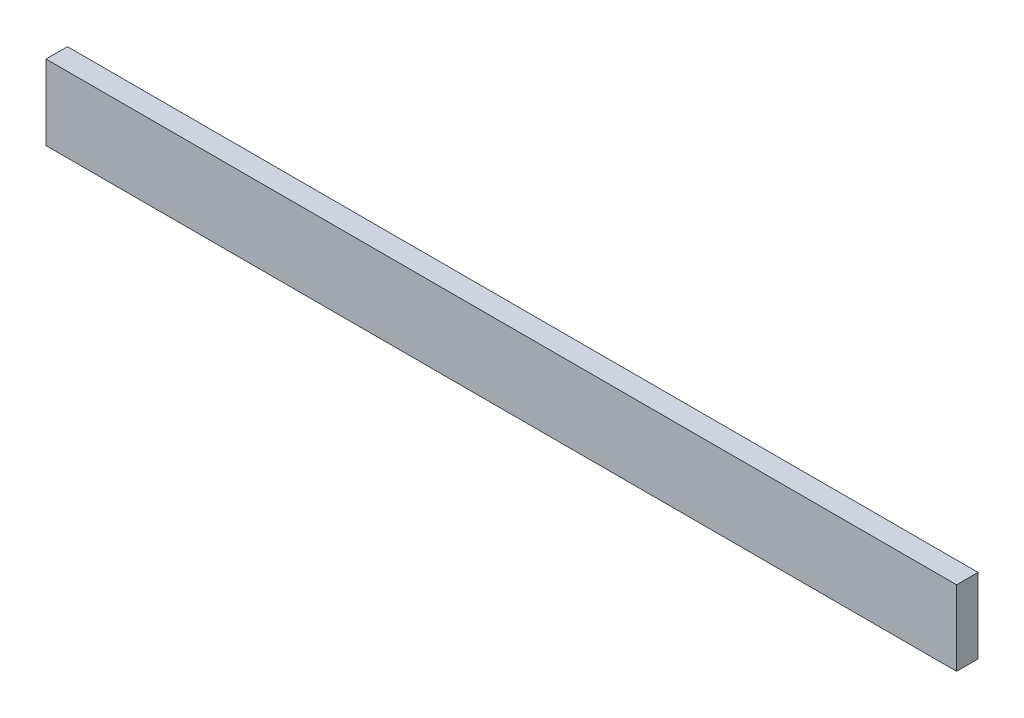
from build123d import *

# Parameters (mm, degrees)
SKETCH1_W           = 85
SKETCH1_H           = 7
BOSS_EXTRUDE1_DEPTH = 2


with BuildPart() as part:
    # Sketch1 → Boss-Extrude1 (new body)
    with BuildSketch(Plane.XY):
        with Locations((42.5, 3.5)):
            Rectangle(SKETCH1_W, SKETCH1_H)
    extrude(amount=BOSS_EXTRUDE1_DEPTH)


solid = part.part
